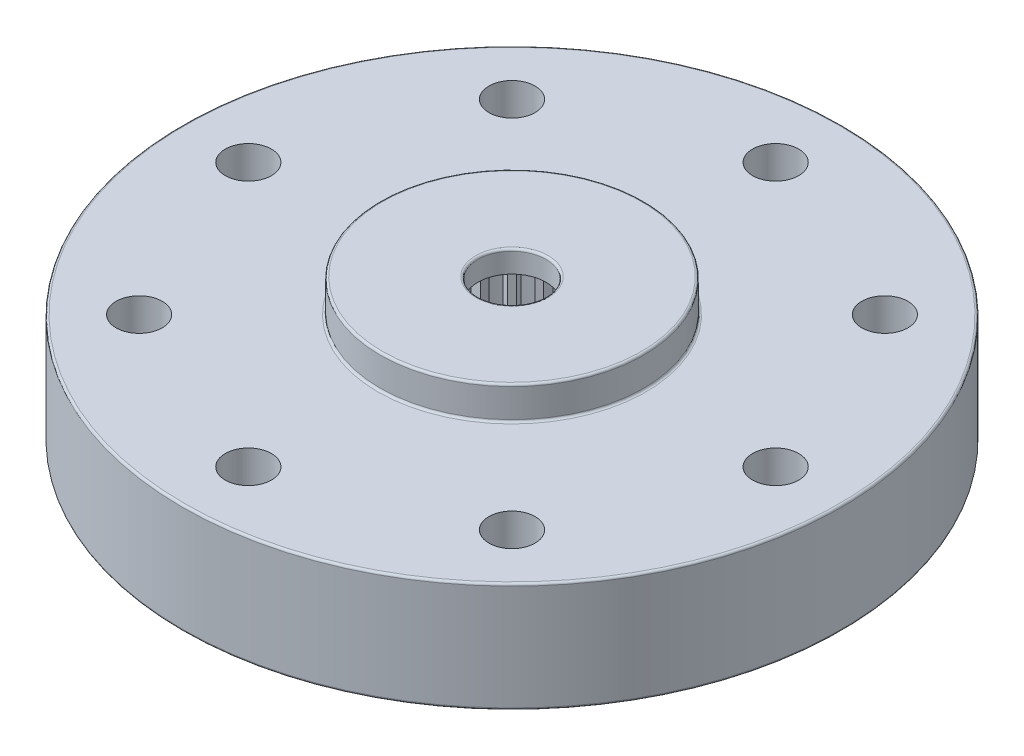
from build123d import *

# Parameters (mm, degrees)
ESQUISSE2_R                        = 15
ESQUISSE2_R_2                      = 1.55
BOSS_EXTRU_1_DEPTH                 = 6.5
ESQUISSE3_R                        = 15
ESQUISSE3_R_2                      = 6
ENL_V_MAT_EXTRU_1_DEPTH            = 1.5
CONG_1_R                           = 0.1
ESQUISSE4_R                        = 1.05
ENL_V_MAT_EXTRU_2_DEPTH            = 5
R_P_TITION_CIRCULAIRE1_COUNT       = 8
ESQUISSE5_R                        = 4
ENL_V_MAT_EXTRU_3_DEPTH            = 5.5
ENL_V_MAT_EXTRU_4_DEPTH            = 2.5
CONG_2_R                           = 0.25
R_P_TITION_CIRCULAIRE2_COUNT       = 4
CONG_2_OF_R_P_TITION_CIRCULAIRE2_R = 0.25
BOSS_EXTRU_2_DEPTH                 = 5.5
R_P_TITION_CIRCULAIRE3_COUNT       = 24


with BuildPart() as part:
    # Esquisse2 → Boss.-Extru.1 (new body)
    with BuildSketch(Plane(origin=(0, 0, 0), x_dir=(1, 0, 0), z_dir=(0, 1, 0))):
        Circle(ESQUISSE2_R)
        Circle(ESQUISSE2_R_2, mode=Mode.SUBTRACT)
    extrude(amount=BOSS_EXTRU_1_DEPTH)

    # Esquisse3 → Enlèv. mat.-Extru.1 (cut)
    with BuildSketch(Plane(origin=(0, 6.5, 0), x_dir=(1, 0, 0), z_dir=(0, 1, 0))):
        Circle(ESQUISSE3_R)
        Circle(ESQUISSE3_R_2, mode=Mode.SUBTRACT)
    extrude(amount=-ENL_V_MAT_EXTRU_1_DEPTH, mode=Mode.SUBTRACT)

    # Congé1
    cong_1_edges = [part.edges().sort_by_distance(p)[0] for p in [
        (-15, 5, 0),
        (-6, 5, 0),
        (-6, 6.5, 0),
        (-15, 0, 0),
        (-1.55, 6.5, 0),
    ]]
    fillet(cong_1_edges, radius=CONG_1_R)

    # Esquisse4 → Enlèv. mat.-Extru.2 (cut)
    with BuildSketch(Plane.XZ):
        with Locations((0, 12)):
            Circle(ESQUISSE4_R)
    enl_v_mat_extru_2 = extrude(amount=-ENL_V_MAT_EXTRU_2_DEPTH, mode=Mode.SUBTRACT)

    # Répétition circulaire1: Enlèv. mat.-Extru.2 ×8 about axis
    r_p_tition_circulaire1_axis = Axis((0, 0, 0), (0, 1, 0))
    for i in range(1, R_P_TITION_CIRCULAIRE1_COUNT):
        add(enl_v_mat_extru_2.rotate(r_p_tition_circulaire1_axis, i * 360 / R_P_TITION_CIRCULAIRE1_COUNT), mode=Mode.SUBTRACT)

    # Esquisse5 → Enlèv. mat.-Extru.3 (cut)
    with BuildSketch(Plane.XZ):
        Circle(ESQUISSE5_R)
    extrude(amount=-ENL_V_MAT_EXTRU_3_DEPTH, mode=Mode.SUBTRACT)

    # Esquisse6 → Enlèv. mat.-Extru.4 (cut)
    with BuildSketch(Plane.XZ):
        with BuildLine():
            Line((1.1, 8.706246951), (1.1, 6.406246951))
            ThreePointArc((1.1, 6.406246951), (4.596194078, 4.596194078), (6.406246951, 1.1))
            Line((6.406246951, 1.1), (8.706246951, 1.1))
            ThreePointArc((8.706246951, 1.1), (6.205188796, 6.205188796), (1.1, 8.706246951))
        make_face()
    enl_v_mat_extru_4 = extrude(amount=-ENL_V_MAT_EXTRU_4_DEPTH, mode=Mode.SUBTRACT)

    # Congé2
    cong_2_edges = [part.edges().sort_by_distance(p)[0] for p in [
        (6.406246951, 1.25, 1.1),
        (1.1, 1.25, 6.406246951),
        (1.1, 1.25, 8.706246951),
        (8.706246951, 1.25, 1.1),
    ]]
    fillet(cong_2_edges, radius=CONG_2_R)

    # Répétition circulaire2: Enlèv. mat.-Extru.4 ×4 about axis
    r_p_tition_circulaire2_axis = Axis((0, 0, 0), (0, 1, 0))
    for i in range(1, R_P_TITION_CIRCULAIRE2_COUNT):
        add(enl_v_mat_extru_4.rotate(r_p_tition_circulaire2_axis, i * 360 / R_P_TITION_CIRCULAIRE2_COUNT), mode=Mode.SUBTRACT)

    # Congé2 of Répétition circulaire2
    cong_2_of_r_p_tition_circulaire2_edges = [part.edges().sort_by_distance(p)[0] for p in [
        (1.1, 1.25, -6.406246951),
        (6.406246951, 1.25, -1.1),
        (8.706246951, 1.25, -1.1),
        (1.1, 1.25, -8.706246951),
        (-6.406246951, 1.25, -1.1),
        (-1.1, 1.25, -6.406246951),
        (-1.1, 1.25, -8.706246951),
        (-8.706246951, 1.25, -1.1),
        (-1.1, 1.25, 6.406246951),
        (-6.406246951, 1.25, 1.1),
        (-8.706246951, 1.25, 1.1),
        (-1.1, 1.25, 8.706246951),
    ]]
    fillet(cong_2_of_r_p_tition_circulaire2_edges, radius=CONG_2_OF_R_P_TITION_CIRCULAIRE2_R)

    # Esquisse7 → Boss.-Extru.2 (add)
    with BuildSketch(Plane.XZ):
        Polygon((0.3, 4), (-0.3, 4), (-0.139230485, 3.4), (0.139230485, 3.4), align=None)
    boss_extru_2 = extrude(amount=-BOSS_EXTRU_2_DEPTH)

    # Répétition circulaire3: Boss.-Extru.2 ×24 about axis
    r_p_tition_circulaire3_axis = Axis((0, 0, 0), (0, 1, 0))
    for i in range(1, R_P_TITION_CIRCULAIRE3_COUNT):
        add(boss_extru_2.rotate(r_p_tition_circulaire3_axis, i * 360 / R_P_TITION_CIRCULAIRE3_COUNT))


solid = part.part
